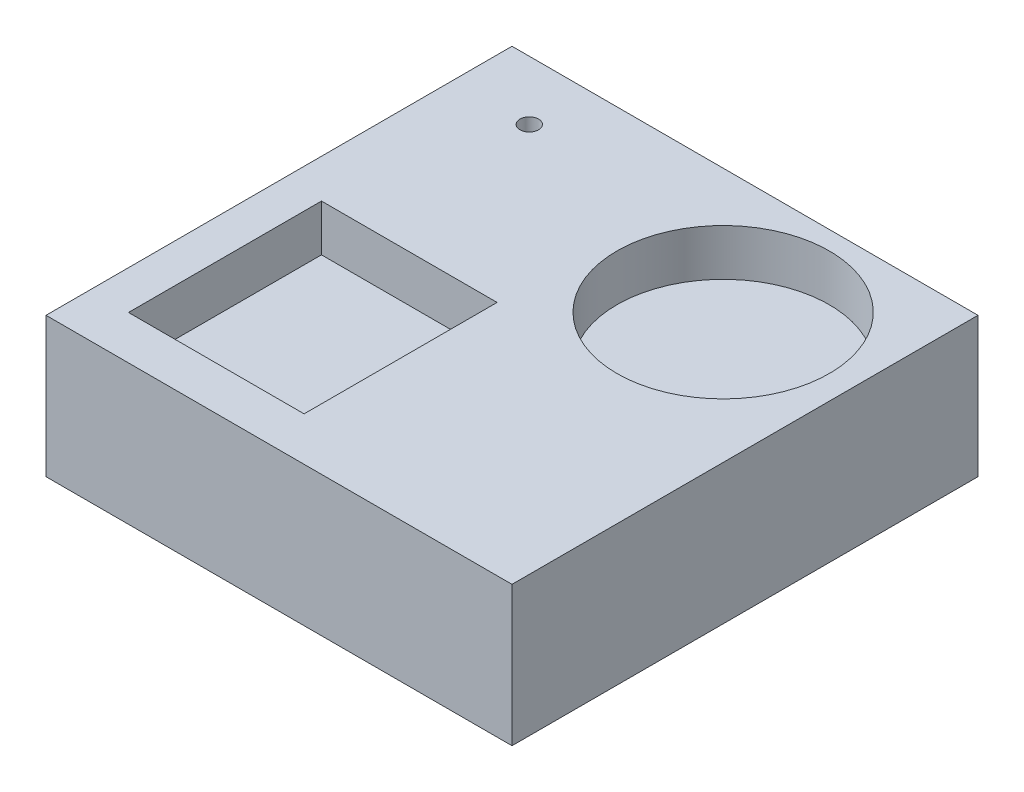
from build123d import *

# Parameters (mm, degrees)
SKETCH1_W           = 100
SKETCH1_H           = 100
BOSS_EXTRUDE1_DEPTH = 30
SKETCH5_R           = 2
CUT_EXTRUDE1_DEPTH  = 31
SKETCH7_R           = 22.78996388
SKETCH7_W           = 37.683489423
SKETCH7_H           = 41.413312703
CUT_EXTRUDE2_DEPTH  = 10


with BuildPart() as part:
    # Sketch1 → Boss-Extrude1 (new body)
    with BuildSketch(Plane(origin=(0, 0, 0), x_dir=(1, 0, 0), z_dir=(0, 1, 0))):
        with Locations((50, 50)):
            Rectangle(SKETCH1_W, SKETCH1_H)
    extrude(amount=BOSS_EXTRUDE1_DEPTH)

    # Sketch5 → Cut-Extrude1 (cut, through all)
    with BuildSketch(Plane(origin=(0, 30, 0), x_dir=(1, 0, 0), z_dir=(0, 1, 0))):
        with Locations((16.384313545, 87.323198024)):
            Circle(SKETCH5_R)
    extrude(amount=-CUT_EXTRUDE1_DEPTH, mode=Mode.SUBTRACT)

    # Sketch7 → Cut-Extrude2 (cut)
    with BuildSketch(Plane(origin=(0, 30, 0), x_dir=(1, 0, 0), z_dir=(0, 1, 0))):
        with Locations((72.084640228, 73.225170758)):
            Circle(SKETCH7_R)
        with Locations((27.16963915, 30.080771209)):
            Rectangle(SKETCH7_W, SKETCH7_H)
    extrude(amount=-CUT_EXTRUDE2_DEPTH, mode=Mode.SUBTRACT)


solid = part.part
